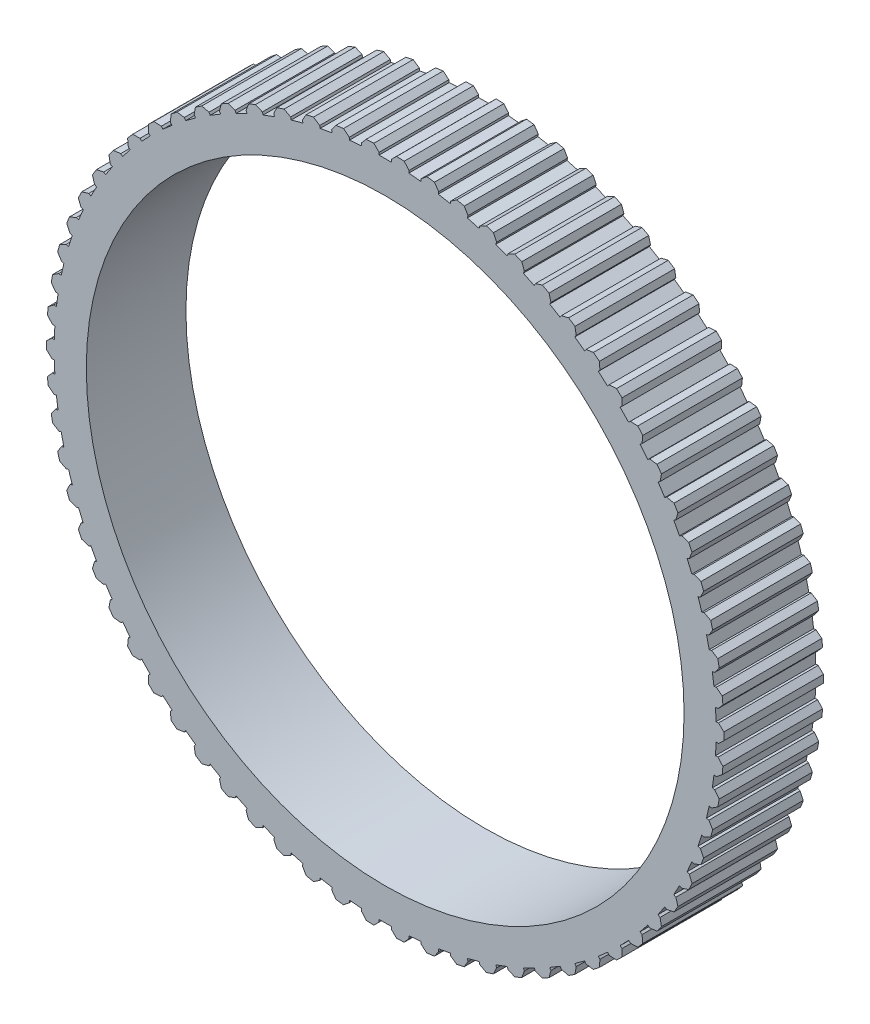
from build123d import *

# Parameters (mm, degrees)
SKETCH1_R           = 45
BOSS_EXTRUDE1_DEPTH = 15


with BuildPart() as part:
    # Sketch1 → Boss-Extrude1 (new body)
    with BuildSketch(Plane.XY):
        with BuildLine():
            Line((-2.859960345, 50.919746924), (-3.586613599, 50.071842109))
            Line((-3.586613599, 50.071842109), (-3.553778014, 49.707008877))
            Line((-3.553778014, 49.707008877), (-5.378861816, 49.542748362))
            Line((-5.378861816, 49.542748362), (-5.411697401, 49.907581594))
            Line((-5.411697401, 49.907581594), (-6.278072289, 50.612111281))
            ThreePointArc((-6.278072289, 50.612111281), (-6.845896557, 50.53843785), (-7.41285791, 50.458394124))
            Line((-7.41285791, 50.458394124), (-8.06058027, 49.54876603))
            Line((-8.06058027, 49.54876603), (-7.995173472, 49.188344868))
            Line((-7.995173472, 49.188344868), (-9.798185824, 48.861146367))
            Line((-9.798185824, 48.861146367), (-9.863592621, 49.221567528))
            Line((-9.863592621, 49.221567528), (-10.789633293, 49.84559974))
            ThreePointArc((-10.789633293, 49.84559974), (-11.348567632, 49.721323521), (-11.906071501, 49.590780004))
            Line((-11.906071501, 49.590780004), (-12.469647887, 48.62675242))
            Line((-12.469647887, 48.62675242), (-12.372196494, 48.273645228))
            Line((-12.372196494, 48.273645228), (-14.138620601, 47.786143151))
            Line((-14.138620601, 47.786143151), (-14.236071994, 48.139250343))
            Line((-14.236071994, 48.139250343), (-15.214322514, 48.677760738))
            ThreePointArc((-15.214322514, 48.677760738), (-15.759866713, 48.503882331), (-16.303424405, 48.323890082))
            Line((-16.303424405, 48.323890082), (-16.778317232, 47.313224792))
            Line((-16.778317232, 47.313224792), (-16.649605865, 46.970274581))
            Line((-16.649605865, 46.970274581), (-18.365219518, 46.326394008))
            Line((-18.365219518, 46.326394008), (-18.493930885, 46.669344218))
            Line((-18.493930885, 46.669344218), (-19.516514956, 47.117997029))
            ThreePointArc((-19.516514956, 47.117997029), (-20.044276614, 46.8959164), (-20.569511722, 46.667924611))
            Line((-20.569511722, 46.667924611), (-20.951897432, 45.618758898))
            Line((-20.951897432, 45.618758898), (-20.792962399, 45.288726902))
            Line((-20.792962399, 45.288726902), (-22.443952486, 44.49365198))
            Line((-22.443952486, 44.49365198), (-22.602887519, 44.823683976))
            Line((-22.602887519, 44.823683976), (-23.661571895, 45.178866912))
            ThreePointArc((-23.661571895, 45.178866912), (-24.167301786, 44.910372125), (-24.669985425, 44.636216452))
            Line((-24.669985425, 44.636216452), (-24.956785273, 43.55699758))
            Line((-24.956785273, 43.55699758), (-24.768906226, 43.242541022))
            Line((-24.768906226, 43.242541022), (-26.341979946, 42.302673228))
            Line((-26.341979946, 42.302673228), (-26.529858993, 42.617129786))
            Line((-26.529858993, 42.617129786), (-27.61611977, 42.875983124))
            ThreePointArc((-27.61611977, 42.875983124), (-28.095746054, 42.56323594), (-28.571830911, 42.245123723))
            Line((-28.571830911, 42.245123723), (-28.760735754, 41.144540929))
            Line((-28.760735754, 41.144540929), (-28.545425384, 40.848191629))
            Line((-28.545425384, 40.848191629), (-30.027917272, 39.771098225))
            Line((-30.027917272, 39.771098225), (-30.243227642, 40.067447525))
            Line((-30.243227642, 40.067447525), (-31.348318886, 40.227887131))
            ThreePointArc((-31.348318886, 40.227887131), (-31.797979895, 39.873405606), (-32.243632815, 39.513898098))
            Line((-32.243632815, 39.513898098), (-32.333121701, 38.400812627))
            Line((-32.333121701, 38.400812627), (-32.092113561, 38.124956615))
            Line((-32.092113561, 38.124956615), (-33.472087464, 36.919309724))
            Line((-33.472087464, 36.919309724), (-33.713095604, 37.195165736))
            Line((-33.713095604, 37.195165736), (-34.828119772, 37.255899844))
            ThreePointArc((-34.828119772, 37.255899844), (-35.244195098, 36.862538055), (-35.655827947, 36.464529799))
            Line((-35.655827947, 36.464529799), (-35.645180364, 35.347903561))
            Line((-35.645180364, 35.347903561), (-35.38041491, 35.094761867))
            Line((-35.38041491, 35.094761867), (-36.64676009, 33.770268649))
            Line((-36.64676009, 33.770268649), (-36.911525544, 34.023410343))
            Line((-36.911525544, 34.023410343), (-38.027505116, 33.983949957))
            ThreePointArc((-38.027505116, 33.983949957), (-38.406644766, 33.554875023), (-38.780943317, 33.121570547))
            Line((-38.780943317, 33.121570547), (-38.670244994, 32.01039396))
            Line((-38.670244994, 32.01039396), (-38.383853961, 31.782004732))
            Line((-38.383853961, 31.782004732), (-39.526374551, 30.349329228))
            Line((-39.526374551, 30.349329228), (-39.812765584, 30.577718455))
            Line((-39.812765584, 30.577718455), (-40.920715348, 30.438381288))
            ThreePointArc((-40.920715348, 30.438381288), (-41.259866713, 29.977047867), (-41.593817334, 29.511935884))
            Line((-41.593817334, 29.511935884), (-41.383959549, 28.415155488))
            Line((-41.383959549, 28.415155488), (-41.078248789, 28.213357583))
            Line((-41.078248789, 28.213357583), (-42.087745885, 26.684034852))
            Line((-42.087745885, 26.684034852), (-42.393456644, 26.885832758))
            Line((-42.393456644, 26.885832758), (-43.484456041, 26.64774067))
            ThreePointArc((-43.484456041, 26.64774067), (-43.780888474, 26.157863148), (-44.071802391, 25.664688466))
            Line((-44.071802391, 25.664688466), (-43.764474795, 24.591134893))
            Line((-43.764474795, 24.591134893), (-43.441905712, 24.417553067))
            Line((-43.441905712, 24.417553067), (-44.310251437, 22.803896319))
            Line((-44.310251437, 22.803896319), (-44.632820519, 22.977478144))
            Line((-44.632820519, 22.977478144), (-45.698085463, 22.642548113))
            ThreePointArc((-45.698085463, 22.642548113), (-45.949412263, 22.128070695), (-46.194947208, 21.610804067))
            Line((-46.194947208, 21.610804067), (-45.792624223, 20.569120938))
            Line((-45.792624223, 20.569120938), (-45.455793953, 20.425152772))
            Line((-45.455793953, 20.425152772), (-46.175996898, 18.74015422))
            Line((-46.175996898, 18.74015422), (-46.512827167, 18.884122386))
            Line((-46.512827167, 18.884122386), (-47.54378077, 18.455051072))
            ThreePointArc((-47.54378077, 18.455051072), (-47.747978403, 17.920116028), (-47.946157473, 17.382922181))
            Line((-47.946157473, 17.382922181), (-47.452078366, 16.381496516))
            Line((-47.452078366, 16.381496516), (-47.103698869, 16.268301156))
            Line((-47.103698869, 16.268301156), (-47.669960383, 14.525527419))
            Line((-47.669960383, 14.525527419), (-48.018339879, 14.638722779))
            Line((-48.018339879, 14.638722779), (-49.00668151, 14.118964811))
            ThreePointArc((-49.00668151, 14.118964811), (-49.162105895, 13.567879124), (-49.31133347, 13.015083226))
            Line((-49.31133347, 13.015083226), (-48.729476276, 12.061977917))
            Line((-48.729476276, 12.061977917), (-48.372352499, 11.980466745))
            Line((-48.372352499, 11.980466745), (-48.780113376, 10.193949612))
            Line((-48.780113376, 10.193949612), (-49.137237153, 10.275460784))
            Line((-49.137237153, 10.275460784), (-50.075009267, 9.669200947))
            ThreePointArc((-50.075009267, 9.669200947), (-50.180409019, 9.106401635), (-50.279483605, 8.542454474))
            Line((-50.279483605, 8.542454474), (-49.614533095, 7.645343363))
            Line((-49.614533095, 7.645343363), (-49.251540388, 7.59617266))
            Line((-49.251540388, 7.59617266), (-49.497517579, 5.780296116))
            Line((-49.497517579, 5.780296116), (-49.860510286, 5.82946682))
            Line((-49.860510286, 5.82946682), (-50.740162492, 5.141586363))
            ThreePointArc((-50.740162492, 5.141586363), (-50.794688994, 4.571604754), (-50.842812901, 4.001046901))
            Line((-50.842812901, 4.001046901), (-50.100122866, 3.167153))
            Line((-50.100122866, 3.167153), (-49.734183834, 3.150718659))
            Line((-49.734183834, 3.150718659), (-49.816396875, 1.320103075))
            Line((-49.816396875, 1.320103075), (-50.182335907, 1.336537416))
            Line((-50.182335907, 1.336537416), (-50.996785763, 0.572574748))
            ThreePointArc((-50.996785763, 0.572574748), (-51, 0), (-50.996785763, -0.572574748))
            Line((-50.996785763, -0.572574748), (-50.182335907, -1.336537416))
            Line((-50.182335907, -1.336537416), (-49.816396875, -1.320103075))
            Line((-49.816396875, -1.320103075), (-49.734183834, -3.150718659))
            Line((-49.734183834, -3.150718659), (-50.100122866, -3.167153))
            Line((-50.100122866, -3.167153), (-50.842812901, -4.001046901))
            ThreePointArc((-50.842812901, -4.001046901), (-50.794688994, -4.571604754), (-50.740162492, -5.141586363))
            Line((-50.740162492, -5.141586363), (-49.860510286, -5.82946682))
            Line((-49.860510286, -5.82946682), (-49.497517579, -5.780296116))
            Line((-49.497517579, -5.780296116), (-49.251540388, -7.59617266))
            Line((-49.251540388, -7.59617266), (-49.614533095, -7.645343363))
            Line((-49.614533095, -7.645343363), (-50.279483605, -8.542454474))
            ThreePointArc((-50.279483605, -8.542454474), (-50.180409019, -9.106401635), (-50.075009267, -9.669200947))
            Line((-50.075009267, -9.669200947), (-49.137237153, -10.275460784))
            Line((-49.137237153, -10.275460784), (-48.780113376, -10.193949612))
            Line((-48.780113376, -10.193949612), (-48.372352499, -11.980466745))
            Line((-48.372352499, -11.980466745), (-48.729476276, -12.061977917))
            Line((-48.729476276, -12.061977917), (-49.31133347, -13.015083226))
            ThreePointArc((-49.31133347, -13.015083226), (-49.162105895, -13.567879124), (-49.00668151, -14.118964811))
            Line((-49.00668151, -14.118964811), (-48.018339879, -14.638722779))
            Line((-48.018339879, -14.638722779), (-47.669960383, -14.525527419))
            Line((-47.669960383, -14.525527419), (-47.103698869, -16.268301156))
            Line((-47.103698869, -16.268301156), (-47.452078366, -16.381496516))
            Line((-47.452078366, -16.381496516), (-47.946157473, -17.382922181))
            ThreePointArc((-47.946157473, -17.382922181), (-47.747978403, -17.920116028), (-47.54378077, -18.455051072))
            Line((-47.54378077, -18.455051072), (-46.512827167, -18.884122386))
            Line((-46.512827167, -18.884122386), (-46.175996898, -18.74015422))
            Line((-46.175996898, -18.74015422), (-45.455793953, -20.425152772))
            Line((-45.455793953, -20.425152772), (-45.792624223, -20.569120938))
            Line((-45.792624223, -20.569120938), (-46.194947208, -21.610804067))
            ThreePointArc((-46.194947208, -21.610804067), (-45.949412263, -22.128070695), (-45.698085463, -22.642548113))
            Line((-45.698085463, -22.642548113), (-44.632820519, -22.977478144))
            Line((-44.632820519, -22.977478144), (-44.310251437, -22.803896319))
            Line((-44.310251437, -22.803896319), (-43.441905712, -24.417553067))
            Line((-43.441905712, -24.417553067), (-43.764474795, -24.591134893))
            Line((-43.764474795, -24.591134893), (-44.071802391, -25.664688466))
            ThreePointArc((-44.071802391, -25.664688466), (-43.780888474, -26.157863148), (-43.484456041, -26.64774067))
            Line((-43.484456041, -26.64774067), (-42.393456644, -26.885832758))
            Line((-42.393456644, -26.885832758), (-42.087745885, -26.684034852))
            Line((-42.087745885, -26.684034852), (-41.078248789, -28.213357583))
            Line((-41.078248789, -28.213357583), (-41.383959549, -28.415155488))
            Line((-41.383959549, -28.415155488), (-41.593817334, -29.511935884))
            ThreePointArc((-41.593817334, -29.511935884), (-41.259866713, -29.977047867), (-40.920715348, -30.438381288))
            Line((-40.920715348, -30.438381288), (-39.812765584, -30.577718455))
            Line((-39.812765584, -30.577718455), (-39.526374551, -30.349329228))
            Line((-39.526374551, -30.349329228), (-38.383853961, -31.782004732))
            Line((-38.383853961, -31.782004732), (-38.670244994, -32.01039396))
            Line((-38.670244994, -32.01039396), (-38.780943317, -33.121570547))
            ThreePointArc((-38.780943317, -33.121570547), (-38.406644766, -33.554875023), (-38.027505116, -33.983949957))
            Line((-38.027505116, -33.983949957), (-36.911525544, -34.023410343))
            Line((-36.911525544, -34.023410343), (-36.64676009, -33.770268649))
            Line((-36.64676009, -33.770268649), (-35.38041491, -35.094761867))
            Line((-35.38041491, -35.094761867), (-35.645180364, -35.347903561))
            Line((-35.645180364, -35.347903561), (-35.655827947, -36.464529799))
            ThreePointArc((-35.655827947, -36.464529799), (-35.244195098, -36.862538055), (-34.828119772, -37.255899844))
            Line((-34.828119772, -37.255899844), (-33.713095604, -37.195165736))
            Line((-33.713095604, -37.195165736), (-33.472087464, -36.919309724))
            Line((-33.472087464, -36.919309724), (-32.092113561, -38.124956615))
            Line((-32.092113561, -38.124956615), (-32.333121701, -38.400812627))
            Line((-32.333121701, -38.400812627), (-32.243632815, -39.513898098))
            ThreePointArc((-32.243632815, -39.513898098), (-31.797979895, -39.873405606), (-31.348318886, -40.227887131))
            Line((-31.348318886, -40.227887131), (-30.243227642, -40.067447525))
            Line((-30.243227642, -40.067447525), (-30.027917272, -39.771098225))
            Line((-30.027917272, -39.771098225), (-28.545425384, -40.848191629))
            Line((-28.545425384, -40.848191629), (-28.760735754, -41.144540929))
            Line((-28.760735754, -41.144540929), (-28.571830911, -42.245123723))
            ThreePointArc((-28.571830911, -42.245123723), (-28.095746054, -42.56323594), (-27.61611977, -42.875983124))
            Line((-27.61611977, -42.875983124), (-26.529858993, -42.617129786))
            Line((-26.529858993, -42.617129786), (-26.341979946, -42.302673228))
            Line((-26.341979946, -42.302673228), (-24.768906226, -43.242541022))
            Line((-24.768906226, -43.242541022), (-24.956785273, -43.55699758))
            Line((-24.956785273, -43.55699758), (-24.669985425, -44.636216452))
            ThreePointArc((-24.669985425, -44.636216452), (-24.167301786, -44.910372125), (-23.661571895, -45.178866912))
            Line((-23.661571895, -45.178866912), (-22.602887519, -44.823683976))
            Line((-22.602887519, -44.823683976), (-22.443952486, -44.49365198))
            Line((-22.443952486, -44.49365198), (-20.792962399, -45.288726902))
            Line((-20.792962399, -45.288726902), (-20.951897432, -45.618758898))
            Line((-20.951897432, -45.618758898), (-20.569511722, -46.667924611))
            ThreePointArc((-20.569511722, -46.667924611), (-20.044276614, -46.8959164), (-19.516514956, -47.117997029))
            Line((-19.516514956, -47.117997029), (-18.493930885, -46.669344218))
            Line((-18.493930885, -46.669344218), (-18.365219518, -46.326394008))
            Line((-18.365219518, -46.326394008), (-16.649605865, -46.970274581))
            Line((-16.649605865, -46.970274581), (-16.778317232, -47.313224792))
            Line((-16.778317232, -47.313224792), (-16.303424405, -48.323890082))
            ThreePointArc((-16.303424405, -48.323890082), (-15.759866713, -48.503882331), (-15.214322514, -48.677760738))
            Line((-15.214322514, -48.677760738), (-14.236071994, -48.139250343))
            Line((-14.236071994, -48.139250343), (-14.138620601, -47.786143151))
            Line((-14.138620601, -47.786143151), (-12.372196494, -48.273645228))
            Line((-12.372196494, -48.273645228), (-12.469647887, -48.62675242))
            Line((-12.469647887, -48.62675242), (-11.906071501, -49.590780004))
            ThreePointArc((-11.906071501, -49.590780004), (-11.348567632, -49.721323521), (-10.789633293, -49.84559974))
            Line((-10.789633293, -49.84559974), (-9.863592621, -49.221567528))
            Line((-9.863592621, -49.221567528), (-9.798185824, -48.861146367))
            Line((-9.798185824, -48.861146367), (-7.995173472, -49.188344868))
            Line((-7.995173472, -49.188344868), (-8.06058027, -49.54876603))
            Line((-8.06058027, -49.54876603), (-7.41285791, -50.458394124))
            ThreePointArc((-7.41285791, -50.458394124), (-6.845896557, -50.53843785), (-6.278072289, -50.612111281))
            Line((-6.278072289, -50.612111281), (-5.411697401, -49.907581594))
            Line((-5.411697401, -49.907581594), (-5.378861816, -49.542748362))
            Line((-5.378861816, -49.542748362), (-3.553778014, -49.707008877))
            Line((-3.553778014, -49.707008877), (-3.586613599, -50.071842109))
            Line((-3.586613599, -50.071842109), (-2.859960345, -50.919746924))
            ThreePointArc((-2.859960345, -50.919746924), (-2.288106348, -50.948646394), (-1.715963938, -50.971123862))
            Line((-1.715963938, -50.971123862), (-0.916230375, -50.191769158))
            Line((-0.916230375, -50.191769158), (-0.916230375, -49.825461278))
            Line((-0.916230375, -49.825461278), (0.916230375, -49.825461278))
            Line((0.916230375, -49.825461278), (0.916230375, -50.191769158))
            Line((0.916230375, -50.191769158), (1.715963938, -50.971123862))
            ThreePointArc((1.715963938, -50.971123862), (2.288106348, -50.948646394), (2.859960345, -50.919746924))
            Line((2.859960345, -50.919746924), (3.586613599, -50.071842109))
            Line((3.586613599, -50.071842109), (3.553778014, -49.707008877))
            Line((3.553778014, -49.707008877), (5.378861816, -49.542748362))
            Line((5.378861816, -49.542748362), (5.411697401, -49.907581594))
            Line((5.411697401, -49.907581594), (6.278072289, -50.612111281))
            ThreePointArc((6.278072289, -50.612111281), (6.845896557, -50.53843785), (7.41285791, -50.458394124))
            Line((7.41285791, -50.458394124), (8.06058027, -49.54876603))
            Line((8.06058027, -49.54876603), (7.995173472, -49.188344868))
            Line((7.995173472, -49.188344868), (9.798185824, -48.861146367))
            Line((9.798185824, -48.861146367), (9.863592621, -49.221567528))
            Line((9.863592621, -49.221567528), (10.789633293, -49.84559974))
            ThreePointArc((10.789633293, -49.84559974), (11.348567632, -49.721323521), (11.906071501, -49.590780004))
            Line((11.906071501, -49.590780004), (12.469647887, -48.62675242))
            Line((12.469647887, -48.62675242), (12.372196494, -48.273645228))
            Line((12.372196494, -48.273645228), (14.138620601, -47.786143151))
            Line((14.138620601, -47.786143151), (14.236071994, -48.139250343))
            Line((14.236071994, -48.139250343), (15.214322514, -48.677760738))
            ThreePointArc((15.214322514, -48.677760738), (15.759866713, -48.503882331), (16.303424405, -48.323890082))
            Line((16.303424405, -48.323890082), (16.778317232, -47.313224792))
            Line((16.778317232, -47.313224792), (16.649605865, -46.970274581))
            Line((16.649605865, -46.970274581), (18.365219518, -46.326394008))
            Line((18.365219518, -46.326394008), (18.493930885, -46.669344218))
            Line((18.493930885, -46.669344218), (19.516514956, -47.117997029))
            ThreePointArc((19.516514956, -47.117997029), (20.044276614, -46.8959164), (20.569511722, -46.667924611))
            Line((20.569511722, -46.667924611), (20.951897432, -45.618758898))
            Line((20.951897432, -45.618758898), (20.792962399, -45.288726902))
            Line((20.792962399, -45.288726902), (22.443952486, -44.49365198))
            Line((22.443952486, -44.49365198), (22.602887519, -44.823683976))
            Line((22.602887519, -44.823683976), (23.661571895, -45.178866912))
            ThreePointArc((23.661571895, -45.178866912), (24.167301786, -44.910372125), (24.669985425, -44.636216452))
            Line((24.669985425, -44.636216452), (24.956785273, -43.55699758))
            Line((24.956785273, -43.55699758), (24.768906226, -43.242541022))
            Line((24.768906226, -43.242541022), (26.341979946, -42.302673228))
            Line((26.341979946, -42.302673228), (26.529858993, -42.617129786))
            Line((26.529858993, -42.617129786), (27.61611977, -42.875983124))
            ThreePointArc((27.61611977, -42.875983124), (28.095746054, -42.56323594), (28.571830911, -42.245123723))
            Line((28.571830911, -42.245123723), (28.760735754, -41.144540929))
            Line((28.760735754, -41.144540929), (28.545425384, -40.848191629))
            Line((28.545425384, -40.848191629), (30.027917272, -39.771098225))
            Line((30.027917272, -39.771098225), (30.243227642, -40.067447525))
            Line((30.243227642, -40.067447525), (31.348318886, -40.227887131))
            ThreePointArc((31.348318886, -40.227887131), (31.797979895, -39.873405606), (32.243632815, -39.513898098))
            Line((32.243632815, -39.513898098), (32.333121701, -38.400812627))
            Line((32.333121701, -38.400812627), (32.092113561, -38.124956615))
            Line((32.092113561, -38.124956615), (33.472087464, -36.919309724))
            Line((33.472087464, -36.919309724), (33.713095604, -37.195165736))
            Line((33.713095604, -37.195165736), (34.828119772, -37.255899844))
            ThreePointArc((34.828119772, -37.255899844), (35.244195098, -36.862538055), (35.655827947, -36.464529799))
            Line((35.655827947, -36.464529799), (35.645180364, -35.347903561))
            Line((35.645180364, -35.347903561), (35.38041491, -35.094761867))
            Line((35.38041491, -35.094761867), (36.64676009, -33.770268649))
            Line((36.64676009, -33.770268649), (36.911525544, -34.023410343))
            Line((36.911525544, -34.023410343), (38.027505116, -33.983949957))
            ThreePointArc((38.027505116, -33.983949957), (38.406644766, -33.554875023), (38.780943317, -33.121570547))
            Line((38.780943317, -33.121570547), (38.670244994, -32.01039396))
            Line((38.670244994, -32.01039396), (38.383853961, -31.782004732))
            Line((38.383853961, -31.782004732), (39.526374551, -30.349329228))
            Line((39.526374551, -30.349329228), (39.812765584, -30.577718455))
            Line((39.812765584, -30.577718455), (40.920715348, -30.438381288))
            ThreePointArc((40.920715348, -30.438381288), (41.259866713, -29.977047867), (41.593817334, -29.511935884))
            Line((41.593817334, -29.511935884), (41.383959549, -28.415155488))
            Line((41.383959549, -28.415155488), (41.078248789, -28.213357583))
            Line((41.078248789, -28.213357583), (42.087745885, -26.684034852))
            Line((42.087745885, -26.684034852), (42.393456644, -26.885832758))
            Line((42.393456644, -26.885832758), (43.484456041, -26.64774067))
            ThreePointArc((43.484456041, -26.64774067), (43.780888474, -26.157863148), (44.071802391, -25.664688466))
            Line((44.071802391, -25.664688466), (43.764474795, -24.591134893))
            Line((43.764474795, -24.591134893), (43.441905712, -24.417553067))
            Line((43.441905712, -24.417553067), (44.310251437, -22.803896319))
            Line((44.310251437, -22.803896319), (44.632820519, -22.977478144))
            Line((44.632820519, -22.977478144), (45.698085463, -22.642548113))
            ThreePointArc((45.698085463, -22.642548113), (45.949412263, -22.128070695), (46.194947208, -21.610804067))
            Line((46.194947208, -21.610804067), (45.792624223, -20.569120938))
            Line((45.792624223, -20.569120938), (45.455793953, -20.425152772))
            Line((45.455793953, -20.425152772), (46.175996898, -18.74015422))
            Line((46.175996898, -18.74015422), (46.512827167, -18.884122386))
            Line((46.512827167, -18.884122386), (47.54378077, -18.455051072))
            ThreePointArc((47.54378077, -18.455051072), (47.747978403, -17.920116028), (47.946157473, -17.382922181))
            Line((47.946157473, -17.382922181), (47.452078366, -16.381496516))
            Line((47.452078366, -16.381496516), (47.103698869, -16.268301156))
            Line((47.103698869, -16.268301156), (47.669960383, -14.525527419))
            Line((47.669960383, -14.525527419), (48.018339879, -14.638722779))
            Line((48.018339879, -14.638722779), (49.00668151, -14.118964811))
            ThreePointArc((49.00668151, -14.118964811), (49.162105895, -13.567879124), (49.31133347, -13.015083226))
            Line((49.31133347, -13.015083226), (48.729476276, -12.061977917))
            Line((48.729476276, -12.061977917), (48.372352499, -11.980466745))
            Line((48.372352499, -11.980466745), (48.780113376, -10.193949612))
            Line((48.780113376, -10.193949612), (49.137237153, -10.275460784))
            Line((49.137237153, -10.275460784), (50.075009267, -9.669200947))
            ThreePointArc((50.075009267, -9.669200947), (50.180409019, -9.106401635), (50.279483605, -8.542454474))
            Line((50.279483605, -8.542454474), (49.614533095, -7.645343363))
            Line((49.614533095, -7.645343363), (49.251540388, -7.59617266))
            Line((49.251540388, -7.59617266), (49.497517579, -5.780296116))
            Line((49.497517579, -5.780296116), (49.860510286, -5.82946682))
            Line((49.860510286, -5.82946682), (50.740162492, -5.141586363))
            ThreePointArc((50.740162492, -5.141586363), (50.794688994, -4.571604754), (50.842812901, -4.001046901))
            Line((50.842812901, -4.001046901), (50.100122866, -3.167153))
            Line((50.100122866, -3.167153), (49.734183834, -3.150718659))
            Line((49.734183834, -3.150718659), (49.816396875, -1.320103075))
            Line((49.816396875, -1.320103075), (50.182335907, -1.336537416))
            Line((50.182335907, -1.336537416), (50.996785763, -0.572574748))
            ThreePointArc((50.996785763, -0.572574748), (51, 0), (50.996785763, 0.572574748))
            Line((50.996785763, 0.572574748), (50.182335907, 1.336537416))
            Line((50.182335907, 1.336537416), (49.816396875, 1.320103075))
            Line((49.816396875, 1.320103075), (49.734183834, 3.150718659))
            Line((49.734183834, 3.150718659), (50.100122866, 3.167153))
            Line((50.100122866, 3.167153), (50.842812901, 4.001046901))
            ThreePointArc((50.842812901, 4.001046901), (50.794688994, 4.571604754), (50.740162492, 5.141586363))
            Line((50.740162492, 5.141586363), (49.860510286, 5.82946682))
            Line((49.860510286, 5.82946682), (49.497517579, 5.780296116))
            Line((49.497517579, 5.780296116), (49.251540388, 7.59617266))
            Line((49.251540388, 7.59617266), (49.614533095, 7.645343363))
            Line((49.614533095, 7.645343363), (50.279483605, 8.542454474))
            ThreePointArc((50.279483605, 8.542454474), (50.180409019, 9.106401635), (50.075009267, 9.669200947))
            Line((50.075009267, 9.669200947), (49.137237153, 10.275460784))
            Line((49.137237153, 10.275460784), (48.780113376, 10.193949612))
            Line((48.780113376, 10.193949612), (48.372352499, 11.980466745))
            Line((48.372352499, 11.980466745), (48.729476276, 12.061977917))
            Line((48.729476276, 12.061977917), (49.31133347, 13.015083226))
            ThreePointArc((49.31133347, 13.015083226), (49.162105895, 13.567879124), (49.00668151, 14.118964811))
            Line((49.00668151, 14.118964811), (48.018339879, 14.638722779))
            Line((48.018339879, 14.638722779), (47.669960383, 14.525527419))
            Line((47.669960383, 14.525527419), (47.103698869, 16.268301156))
            Line((47.103698869, 16.268301156), (47.452078366, 16.381496516))
            Line((47.452078366, 16.381496516), (47.946157473, 17.382922181))
            ThreePointArc((47.946157473, 17.382922181), (47.747978403, 17.920116028), (47.54378077, 18.455051072))
            Line((47.54378077, 18.455051072), (46.512827167, 18.884122386))
            Line((46.512827167, 18.884122386), (46.175996898, 18.74015422))
            Line((46.175996898, 18.74015422), (45.455793953, 20.425152772))
            Line((45.455793953, 20.425152772), (45.792624223, 20.569120938))
            Line((45.792624223, 20.569120938), (46.194947208, 21.610804067))
            ThreePointArc((46.194947208, 21.610804067), (45.949412263, 22.128070695), (45.698085463, 22.642548113))
            Line((45.698085463, 22.642548113), (44.632820519, 22.977478144))
            Line((44.632820519, 22.977478144), (44.310251437, 22.803896319))
            Line((44.310251437, 22.803896319), (43.441905712, 24.417553067))
            Line((43.441905712, 24.417553067), (43.764474795, 24.591134893))
            Line((43.764474795, 24.591134893), (44.071802391, 25.664688466))
            ThreePointArc((44.071802391, 25.664688466), (43.780888474, 26.157863148), (43.484456041, 26.64774067))
            Line((43.484456041, 26.64774067), (42.393456644, 26.885832758))
            Line((42.393456644, 26.885832758), (42.087745885, 26.684034852))
            Line((42.087745885, 26.684034852), (41.078248789, 28.213357583))
            Line((41.078248789, 28.213357583), (41.383959549, 28.415155488))
            Line((41.383959549, 28.415155488), (41.593817334, 29.511935884))
            ThreePointArc((41.593817334, 29.511935884), (41.259866713, 29.977047867), (40.920715348, 30.438381288))
            Line((40.920715348, 30.438381288), (39.812765584, 30.577718455))
            Line((39.812765584, 30.577718455), (39.526374551, 30.349329228))
            Line((39.526374551, 30.349329228), (38.383853961, 31.782004732))
            Line((38.383853961, 31.782004732), (38.670244994, 32.01039396))
            Line((38.670244994, 32.01039396), (38.780943317, 33.121570547))
            ThreePointArc((38.780943317, 33.121570547), (38.406644766, 33.554875023), (38.027505116, 33.983949957))
            Line((38.027505116, 33.983949957), (36.911525544, 34.023410343))
            Line((36.911525544, 34.023410343), (36.64676009, 33.770268649))
            Line((36.64676009, 33.770268649), (35.38041491, 35.094761867))
            Line((35.38041491, 35.094761867), (35.645180364, 35.347903561))
            Line((35.645180364, 35.347903561), (35.655827947, 36.464529799))
            ThreePointArc((35.655827947, 36.464529799), (35.244195098, 36.862538055), (34.828119772, 37.255899844))
            Line((34.828119772, 37.255899844), (33.713095604, 37.195165736))
            Line((33.713095604, 37.195165736), (33.472087464, 36.919309724))
            Line((33.472087464, 36.919309724), (32.092113561, 38.124956615))
            Line((32.092113561, 38.124956615), (32.333121701, 38.400812627))
            Line((32.333121701, 38.400812627), (32.243632815, 39.513898098))
            ThreePointArc((32.243632815, 39.513898098), (31.797979895, 39.873405606), (31.348318886, 40.227887131))
            Line((31.348318886, 40.227887131), (30.243227642, 40.067447525))
            Line((30.243227642, 40.067447525), (30.027917272, 39.771098225))
            Line((30.027917272, 39.771098225), (28.545425384, 40.848191629))
            Line((28.545425384, 40.848191629), (28.760735754, 41.144540929))
            Line((28.760735754, 41.144540929), (28.571830911, 42.245123723))
            ThreePointArc((28.571830911, 42.245123723), (28.095746054, 42.56323594), (27.61611977, 42.875983124))
            Line((27.61611977, 42.875983124), (26.529858993, 42.617129786))
            Line((26.529858993, 42.617129786), (26.341979946, 42.302673228))
            Line((26.341979946, 42.302673228), (24.768906226, 43.242541022))
            Line((24.768906226, 43.242541022), (24.956785273, 43.55699758))
            Line((24.956785273, 43.55699758), (24.669985425, 44.636216452))
            ThreePointArc((24.669985425, 44.636216452), (24.167301786, 44.910372125), (23.661571895, 45.178866912))
            Line((23.661571895, 45.178866912), (22.602887519, 44.823683976))
            Line((22.602887519, 44.823683976), (22.443952486, 44.49365198))
            Line((22.443952486, 44.49365198), (20.792962399, 45.288726902))
            Line((20.792962399, 45.288726902), (20.951897432, 45.618758898))
            Line((20.951897432, 45.618758898), (20.569511722, 46.667924611))
            ThreePointArc((20.569511722, 46.667924611), (20.044276614, 46.8959164), (19.516514956, 47.117997029))
            Line((19.516514956, 47.117997029), (18.493930885, 46.669344218))
            Line((18.493930885, 46.669344218), (18.365219518, 46.326394008))
            Line((18.365219518, 46.326394008), (16.649605865, 46.970274581))
            Line((16.649605865, 46.970274581), (16.778317232, 47.313224792))
            Line((16.778317232, 47.313224792), (16.303424405, 48.323890082))
            ThreePointArc((16.303424405, 48.323890082), (15.759866713, 48.503882331), (15.214322514, 48.677760738))
            Line((15.214322514, 48.677760738), (14.236071994, 48.139250343))
            Line((14.236071994, 48.139250343), (14.138620601, 47.786143151))
            Line((14.138620601, 47.786143151), (12.372196494, 48.273645228))
            Line((12.372196494, 48.273645228), (12.469647887, 48.62675242))
            Line((12.469647887, 48.62675242), (11.906071501, 49.590780004))
            ThreePointArc((11.906071501, 49.590780004), (11.348567632, 49.721323521), (10.789633293, 49.84559974))
            Line((10.789633293, 49.84559974), (9.863592621, 49.221567528))
            Line((9.863592621, 49.221567528), (9.798185824, 48.861146367))
            Line((9.798185824, 48.861146367), (7.995173472, 49.188344868))
            Line((7.995173472, 49.188344868), (8.06058027, 49.54876603))
            Line((8.06058027, 49.54876603), (7.41285791, 50.458394124))
            ThreePointArc((7.41285791, 50.458394124), (6.845896557, 50.53843785), (6.278072289, 50.612111281))
            Line((6.278072289, 50.612111281), (5.411697401, 49.907581594))
            Line((5.411697401, 49.907581594), (5.378861816, 49.542748362))
            Line((5.378861816, 49.542748362), (3.553778014, 49.707008877))
            Line((3.553778014, 49.707008877), (3.586613599, 50.071842109))
            Line((3.586613599, 50.071842109), (2.859960345, 50.919746924))
            ThreePointArc((2.859960345, 50.919746924), (2.288106348, 50.948646394), (1.715963938, 50.971123862))
            Line((1.715963938, 50.971123862), (0.916230375, 50.191769158))
            Line((0.916230375, 50.191769158), (0.916230375, 49.825461278))
            Line((0.916230375, 49.825461278), (-0.916230375, 49.825461278))
            Line((-0.916230375, 49.825461278), (-0.916230375, 50.191769158))
            Line((-0.916230375, 50.191769158), (-1.715963938, 50.971123862))
            ThreePointArc((-1.715963938, 50.971123862), (-2.288106348, 50.948646394), (-2.859960345, 50.919746924))
        make_face()
        Circle(SKETCH1_R, mode=Mode.SUBTRACT)
    extrude(amount=BOSS_EXTRUDE1_DEPTH)


solid = part.part
